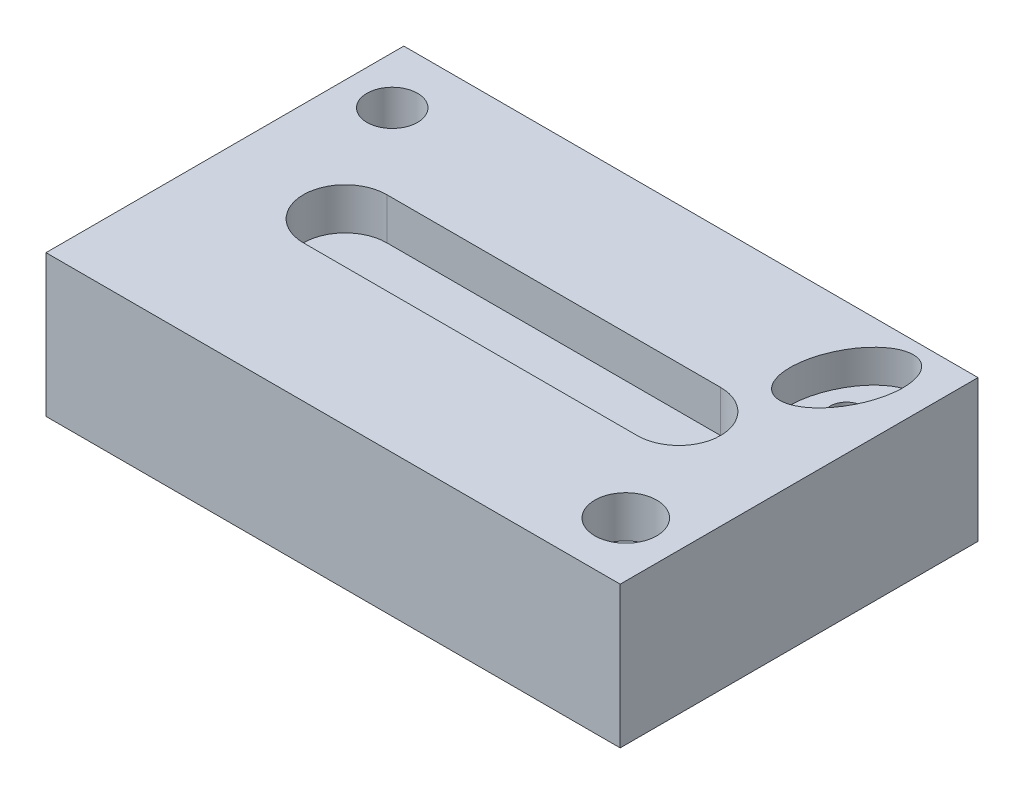
from build123d import *

# Parameters (mm, degrees)
SKETCH1_W           = 174.796166906
SKETCH1_H           = 108.92723011
BOSS_EXTRUDE1_DEPTH = 43.18
SKETCH2_R           = 7.697413188
SKETCH2_R_2         = 9.430807524
CUT_EXTRUDE1_DEPTH  = 12.7
SKETCH3_RX          = 17
SKETCH3_RY          = 10
CUT_EXTRUDE2_DEPTH  = 10
SKETCH4_R           = 5
CUT_EXTRUDE3_DEPTH  = 50


with BuildPart() as part:
    # Sketch1 → Boss-Extrude1 (new body)
    with BuildSketch(Plane(origin=(0, 0, 0), x_dir=(1, 0, 0), z_dir=(0, 1, 0))):
        Rectangle(SKETCH1_W, SKETCH1_H)
    extrude(amount=BOSS_EXTRUDE1_DEPTH)

    # Sketch2 → Cut-Extrude1 (cut)
    with BuildSketch(Plane(origin=(0, 43.18, 0), x_dir=(1, 0, 0), z_dir=(0, 1, 0))):
        with Locations(Location((-72.874036632, 36.40863105, 0), (0, 0, 270))):  # turned: the seam where the file's is
            Circle(SKETCH2_R)
        with Locations(Location((70.801263176, -36.157833353, 0), (0, 0, 270))):  # turned: the seam where the file's is
            Circle(SKETCH2_R_2)
        with BuildLine():
            Line((-50.8, 12.7), (50.8, 12.7))
            ThreePointArc((50.8, 12.7), (63.5, 0), (50.8, -12.7))
            Line((50.8, -12.7), (-50.8, -12.7))
            ThreePointArc((-50.8, -12.7), (-63.5, 0), (-50.8, 12.7))
        make_face()
    extrude(amount=-CUT_EXTRUDE1_DEPTH, mode=Mode.SUBTRACT)

    # Sketch3 → Cut-Extrude2 (cut)
    with BuildSketch(Plane(origin=(0, 43.18, 0), x_dir=(1, 0, 0), z_dir=(0, 1, 0))):
        with Locations(Location((67.398083453, 34.463615055), (0, 0, 67.693794945))):
            Ellipse(SKETCH3_RX, SKETCH3_RY)
    extrude(amount=-CUT_EXTRUDE2_DEPTH, mode=Mode.SUBTRACT)

    # Sketch4 → Cut-Extrude3 (cut)
    with BuildSketch(Plane(origin=(0, 33.18, 0), x_dir=(1, 0, 0), z_dir=(0, 1, 0))):
        with Locations(Location((67.398083453, 34.463615055, 0), (0, 0, 270))):  # turned: the seam where the file's is
            Circle(SKETCH4_R)
    extrude(amount=-CUT_EXTRUDE3_DEPTH, mode=Mode.SUBTRACT)


solid = part.part
